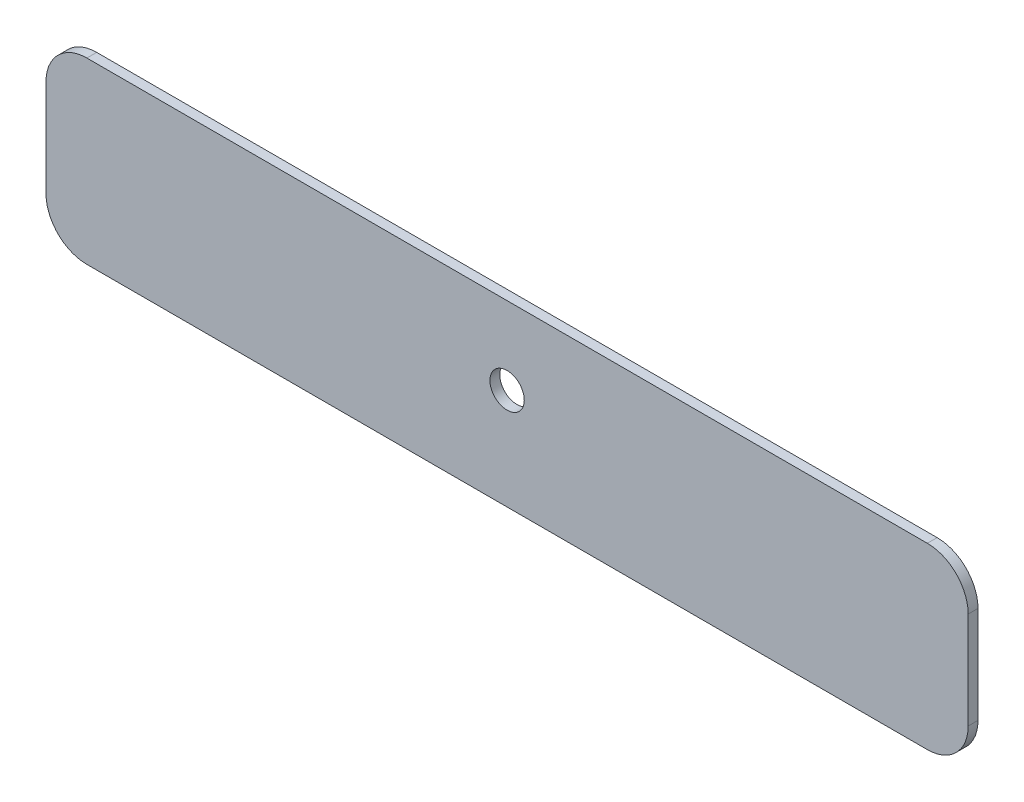
from build123d import *

# Parameters (mm, degrees)
SKETCH1_R           = 2.1
BOSS_EXTRUDE1_DEPTH = 1.2
FILLET1_R           = 5


with BuildPart() as part:
    # Sketch1 → Boss-Extrude1 (new body)
    with BuildSketch(Plane.XY):
        Polygon((-56.4, 136.5), (-56.4, 114.638335016), (56.4, 114.638335016), (56.4, 136.5), (0, 136.5), align=None)
        with Locations((0, 127)):
            Circle(SKETCH1_R, mode=Mode.SUBTRACT)
    extrude(amount=BOSS_EXTRUDE1_DEPTH)

    # Fillet1
    fillet1_edges = [part.edges().sort_by_distance(p)[0] for p in [
        (56.4, 114.638335016, 0.6),
        (-56.4, 114.638335016, 0.6),
        (-56.4, 136.5, 0.6),
        (56.4, 136.5, 0.6),
    ]]
    fillet(fillet1_edges, radius=FILLET1_R)


solid = part.part
